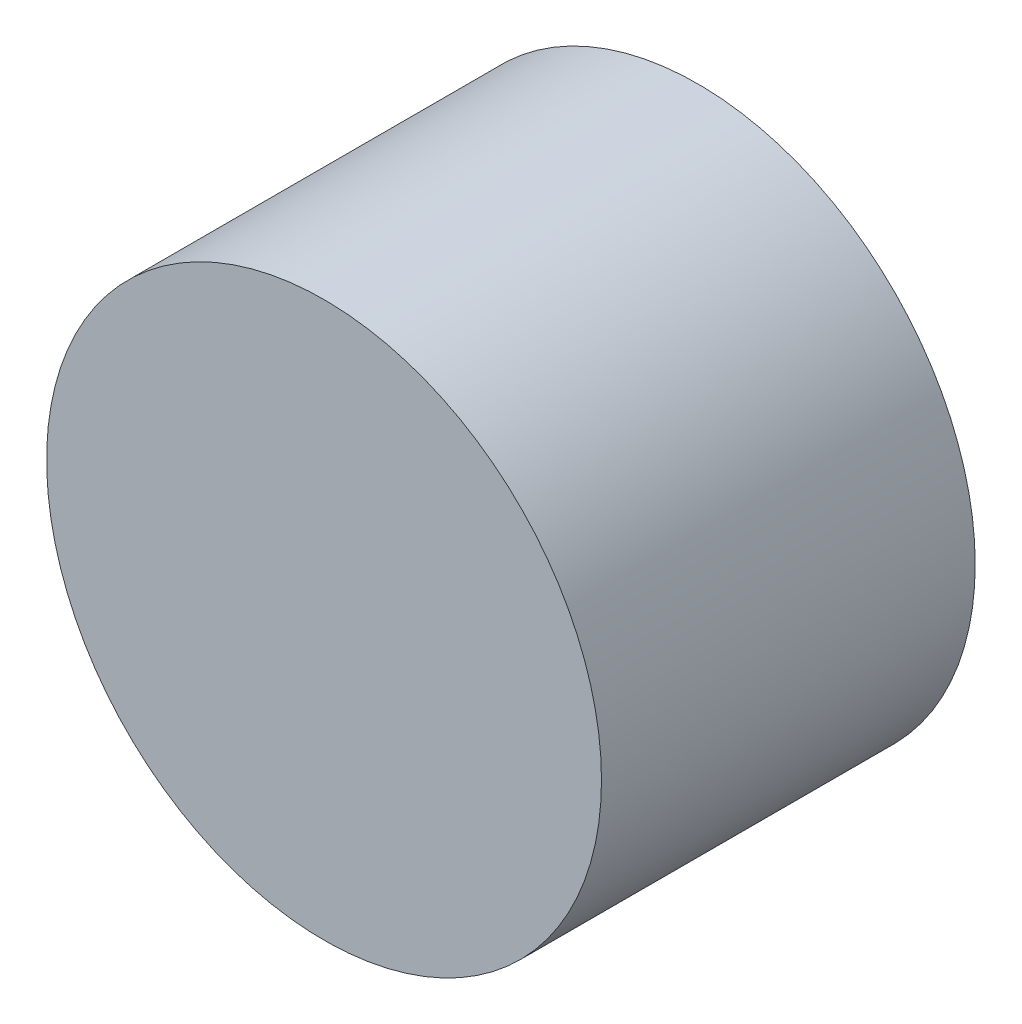
from build123d import *

# Parameters (mm, degrees)
SKETCH1_R           = 11.135926422
BOSS_EXTRUDE1_DEPTH = 15


with BuildPart() as part:
    # Sketch1 → Boss-Extrude1 (new body)
    with BuildSketch(Plane.XY):
        Circle(SKETCH1_R)
    extrude(amount=-BOSS_EXTRUDE1_DEPTH)


solid = part.part
